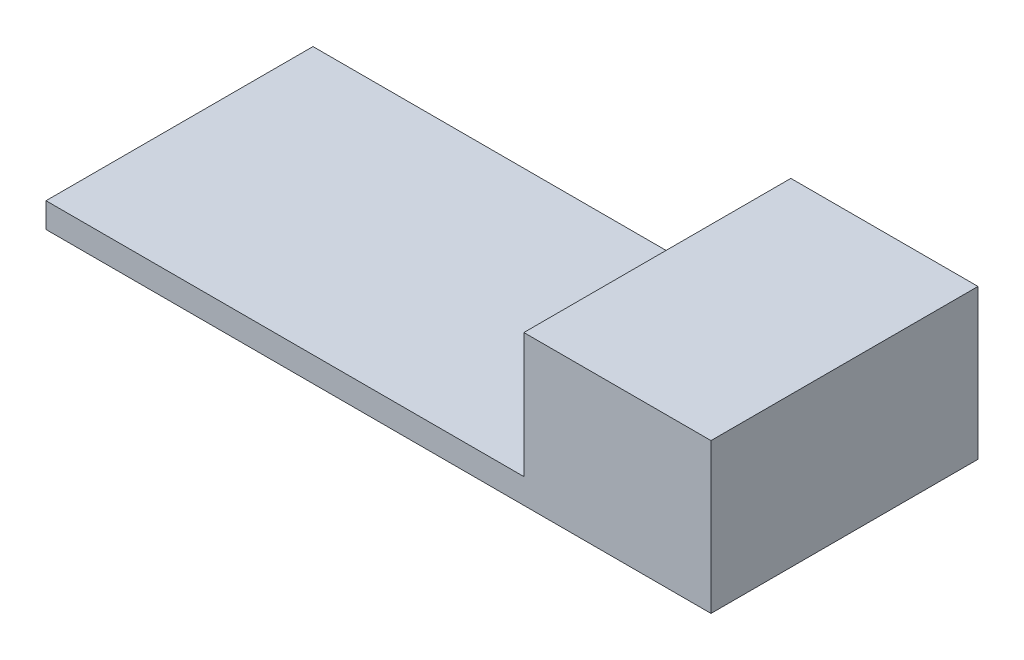
from build123d import *

# Parameters (mm, degrees)
SKETCH1_W           = 53.3
SKETCH1_H           = 21.4
BOSS_EXTRUDE1_DEPTH = 2
SKETCH2_W           = 15
SKETCH2_H           = 21.4
BOSS_EXTRUDE2_DEPTH = 10


with BuildPart() as part:
    # Sketch1 → Boss-Extrude1 (new body)
    with BuildSketch(Plane(origin=(0, 0, 0), x_dir=(1, 0, 0), z_dir=(0, 1, 0))):
        Rectangle(SKETCH1_W, SKETCH1_H)
    extrude(amount=BOSS_EXTRUDE1_DEPTH)

    # Sketch2 → Boss-Extrude2 (add)
    with BuildSketch(Plane(origin=(0, 2, 0), x_dir=(1, 0, 0), z_dir=(0, 1, 0))):
        with Locations((19.15, 0)):
            Rectangle(SKETCH2_W, SKETCH2_H)
    extrude(amount=BOSS_EXTRUDE2_DEPTH)


solid = part.part
